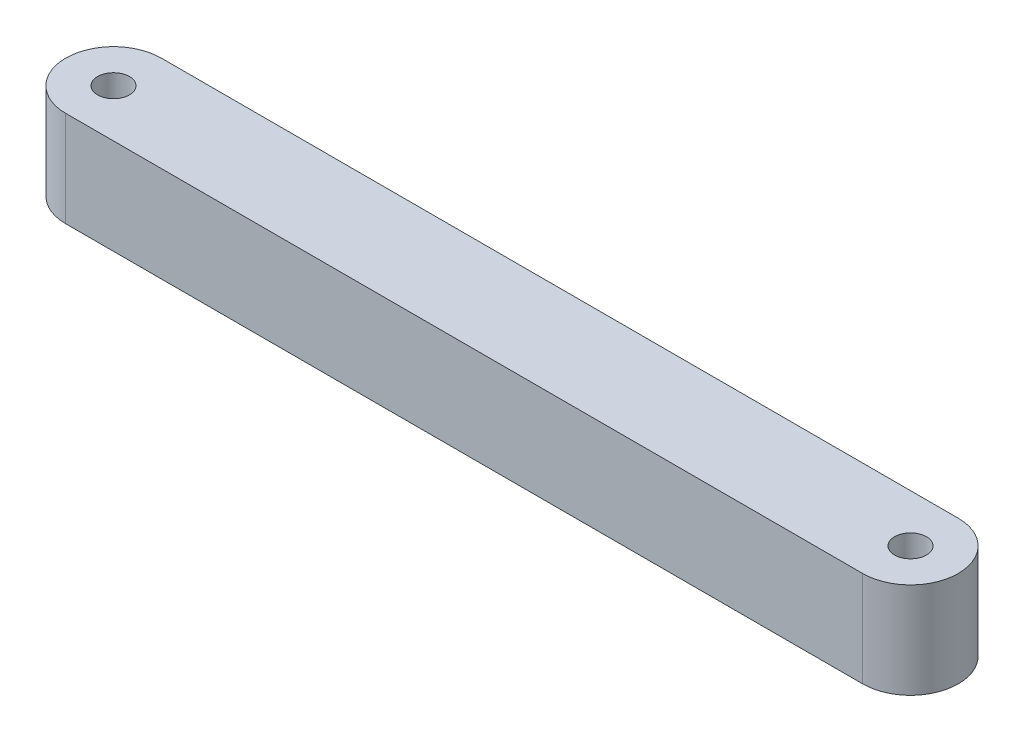
from build123d import *

# Parameters (mm, degrees)
SKETCH1_R           = 3.175
BOSS_EXTRUDE1_DEPTH = 19.05


with BuildPart() as part:
    # Sketch1 → Boss-Extrude1 (new body)
    with BuildSketch(Plane(origin=(0, 0, 0), x_dir=(1, 0, 0), z_dir=(0, 1, 0))):
        with BuildLine():
            Line((-79.375, -9.525), (79.375, -9.525))
            ThreePointArc((79.375, -9.525), (88.9, 0), (79.375, 9.525))
            Line((79.375, 9.525), (-79.375, 9.525))
            ThreePointArc((-79.375, 9.525), (-88.9, 0), (-79.375, -9.525))
        make_face()
        with Locations((-79.375, 0)):
            Circle(SKETCH1_R, mode=Mode.SUBTRACT)
        with Locations((79.375, 0)):
            Circle(SKETCH1_R, mode=Mode.SUBTRACT)
    extrude(amount=BOSS_EXTRUDE1_DEPTH)


solid = part.part
